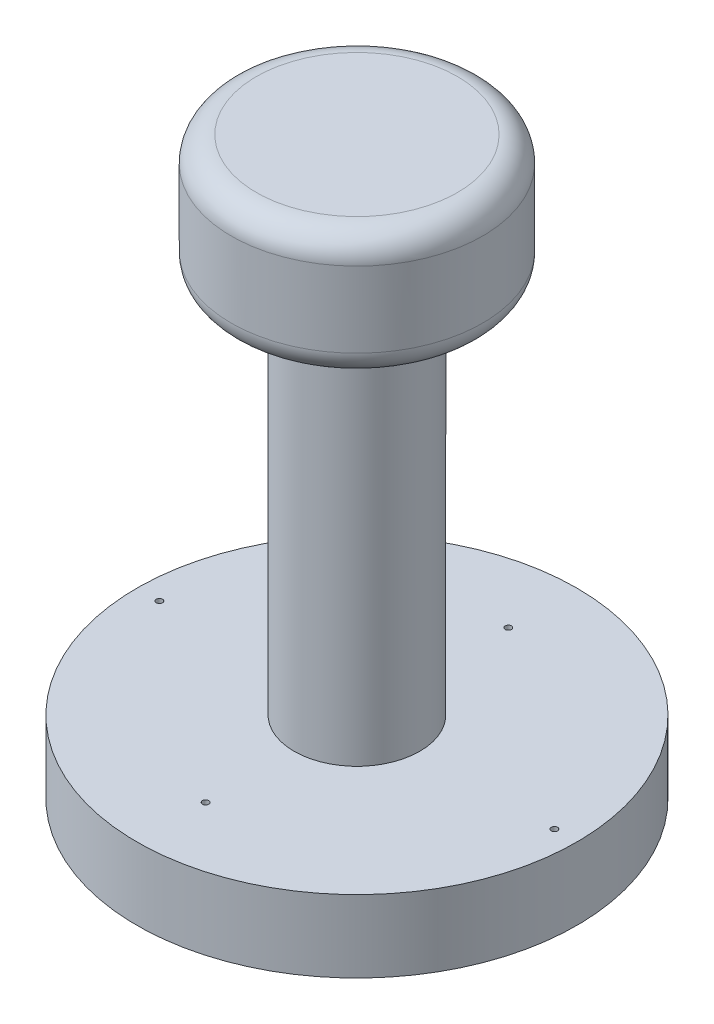
from build123d import *

# Parameters (mm, degrees)
SKETCH1_W            = 10
SKETCH1_H            = 10
FILLET1_R            = 2
FILLET2_R            = 2
SKETCH2_R            = 5
BOSS_EXTRUDE1_DEPTH  = 30
SKETCH3_R            = 17.5
BOSS_EXTRUDE2_DEPTH  = 5
SKETCH4_R            = 17.5
SKETCH4_R_2          = 17.25
BOSS_EXTRUDE4_DEPTH  = 0.75
SKETCH5_W            = 28.357054984
SKETCH5_H            = 13.671265806
SKETCH5_W_2          = 27.36
SKETCH5_H_2          = 12.67056155
BOSS_EXTRUDE5_DEPTH  = 0.75
FILLET3_R            = 2
FILLET4_R            = 2
FILLET5_R            = 2
FILLET6_R            = 2
FILLET9_R            = 2
FILLET10_R           = 2
FILLET11_R           = 2
FILLET12_R           = 2
SKETCH8_W            = 0.5
SKETCH8_H            = 2.723447839
BOSS_EXTRUDE7_DEPTH  = 0.75
SKETCH9_R            = 2.516469436
SKETCH9_R_2          = 1.509887237
SKETCH9_R_3          = 1.01085601
BOSS_EXTRUDE8_DEPTH  = 0.75
FILLET13_R           = 2
FILLET14_R           = 2
BOSS_EXTRUDE10_DEPTH = 0.75
BOSS_EXTRUDE11_DEPTH = 0.75
BOSS_EXTRUDE12_DEPTH = 0.75
BOSS_EXTRUDE14_DEPTH = 0.75
SKETCH20_R           = 0.25
CUT_EXTRUDE1_DEPTH   = 5
SKETCH23_R           = 0.25
CUT_EXTRUDE2_DEPTH   = 5
SKETCH24_R           = 0.25
CUT_EXTRUDE3_DEPTH   = 5
SKETCH25_R           = 0.25
CUT_EXTRUDE4_DEPTH   = 5


with BuildPart() as part:
    # Sketch1 → Revolve1 (revolve)
    with BuildSketch(Plane.XY):
        Rectangle(SKETCH1_W, SKETCH1_H)
    revolve(axis=Axis((5, -5, 0), (0, 1, 0)))

    # Fillet1
    fillet1_edges = [part.edges().sort_by_distance(p)[0] for p in [
        (15, 5, 0),
    ]]
    fillet(fillet1_edges, radius=FILLET1_R)

    # Fillet2
    fillet2_edges = [part.edges().sort_by_distance(p)[0] for p in [
        (15, -5, 0),
    ]]
    fillet(fillet2_edges, radius=FILLET2_R)

    # Sketch2 → Boss-Extrude1 (add)
    with BuildSketch(Plane(origin=(0, -5, 0), x_dir=(-1, 0, 0), z_dir=(0, -1, 0))):
        with Locations((-5, 0)):
            Circle(SKETCH2_R)
    extrude(amount=BOSS_EXTRUDE1_DEPTH)

    # Sketch3 → Boss-Extrude2 (add)
    with BuildSketch(Plane(origin=(0, -35, 0), x_dir=(-1, 0, 0), z_dir=(0, -1, 0))):
        with Locations((-5, 0)):
            Circle(SKETCH3_R)
    extrude(amount=BOSS_EXTRUDE2_DEPTH)

    # Sketch4 → Boss-Extrude4 (add)
    with BuildSketch(Plane(origin=(0, -40, 0), x_dir=(-1, 0, 0), z_dir=(0, -1, 0))):
        with Locations((-5, 0)):
            Circle(SKETCH4_R)
        with Locations((-5, 0)):
            Circle(SKETCH4_R_2, mode=Mode.SUBTRACT)
    extrude(amount=BOSS_EXTRUDE4_DEPTH)

    # Sketch5 → Boss-Extrude5 (add)
    with BuildSketch(Plane(origin=(0, -40, 0), x_dir=(-1, 0, 0), z_dir=(0, -1, 0))):
        with Locations((-5, 0)):
            Rectangle(SKETCH5_W, SKETCH5_H)
        with Locations((-5, 0)):
            Rectangle(SKETCH5_W_2, SKETCH5_H_2, mode=Mode.SUBTRACT)
    extrude(amount=BOSS_EXTRUDE5_DEPTH)

    # Fillet3
    fillet3_edges = [part.edges().sort_by_distance(p)[0] for p in [
        (-8.68, -40.375, 6.335280775),
    ]]
    fillet(fillet3_edges, radius=FILLET3_R)

    # Fillet4
    fillet4_edges = [part.edges().sort_by_distance(p)[0] for p in [
        (-9.178527492, -40.375, 6.835632903),
    ]]
    fillet(fillet4_edges, radius=FILLET4_R)

    # Fillet5
    fillet5_edges = [part.edges().sort_by_distance(p)[0] for p in [
        (18.68, -40.375, 6.335280775),
    ]]
    fillet(fillet5_edges, radius=FILLET5_R)

    # Fillet6
    fillet6_edges = [part.edges().sort_by_distance(p)[0] for p in [
        (19.178527492, -40.375, 6.835632903),
    ]]
    fillet(fillet6_edges, radius=FILLET6_R)

    # Fillet9
    fillet9_edges = [part.edges().sort_by_distance(p)[0] for p in [
        (18.68, -40.375, -6.335280775),
    ]]
    fillet(fillet9_edges, radius=FILLET9_R)

    # Fillet10
    fillet10_edges = [part.edges().sort_by_distance(p)[0] for p in [
        (19.178527492, -40.375, -6.835632903),
    ]]
    fillet(fillet10_edges, radius=FILLET10_R)

    # Fillet11
    fillet11_edges = [part.edges().sort_by_distance(p)[0] for p in [
        (-8.68, -40.375, -6.335280775),
    ]]
    fillet(fillet11_edges, radius=FILLET11_R)

    # Fillet12
    fillet12_edges = [part.edges().sort_by_distance(p)[0] for p in [
        (-9.178527492, -40.375, -6.835632903),
    ]]
    fillet(fillet12_edges, radius=FILLET12_R)

    # Sketch8 → Boss-Extrude7 (add)
    with BuildSketch(Plane.XZ.offset(40)):
        with Locations((-3.698250587, -1.36172392)):
            Rectangle(SKETCH8_W, SKETCH8_H)
        Polygon((-3.448250587, -2.723447839), (-3.948250587, -2.723447839), (-3.948250587, -3.223447839), (7.130563459, -3.223447839), (7.130563459, -2.723447839), align=None)
    extrude(amount=BOSS_EXTRUDE7_DEPTH)

    # Sketch9 → Boss-Extrude8 (add)
    with BuildSketch(Plane(origin=(0, -40, 0), x_dir=(-1, 0, 0), z_dir=(0, -1, 0))):
        with Locations((-17.460950076, -5.133055929)):
            Circle(SKETCH9_R)
        with Locations((-14.94448064, -8.642235551)):
            Circle(SKETCH9_R_2)
        with Locations((-17.969915059, -8.936899488)):
            Circle(SKETCH9_R_3)
    extrude(amount=BOSS_EXTRUDE8_DEPTH)

    # Fillet13
    fillet13_edges = [part.edges().sort_by_distance(p)[0] for p in [
        (-3.448250587, -40.375, -2.723447839),
    ]]
    fillet(fillet13_edges, radius=FILLET13_R)

    # Fillet14
    fillet14_edges = [part.edges().sort_by_distance(p)[0] for p in [
        (-3.948250587, -40.375, -3.223447839),
    ]]
    fillet(fillet14_edges, radius=FILLET14_R)

    # Sketch15 → Boss-Extrude10 (add)
    with BuildSketch(Plane(origin=(0, -40, 0), x_dir=(-1, 0, 0), z_dir=(0, -1, 0))):
        Polygon((-9.246204562, -2.487406617), (-9.246204562, 1.012593383), (-9.312110011, 1.012593383), (-11.62440969, -1.742114149), (-11.62440969, 1.012593383), (-11.938512254, 1.012593383), (-11.938512254, -2.487406617), (-11.866997831, -2.487406617), (-9.560307126, 0.260990819), (-9.560307126, -2.487406617), align=None)
    extrude(amount=BOSS_EXTRUDE10_DEPTH)

    # Sketch16 → Boss-Extrude11 (add)
    with BuildSketch(Plane(origin=(0, -40, 0), x_dir=(-1, 0, 0), z_dir=(0, -1, 0))):
        with BuildLine():
            add(Edge.make_bspline(
                [(-6.96372979, 1.117976908), (-7.028537896, 1.116335429), (-7.155826363, 1.113111428), (-7.34290126, 1.088432325), (-7.521496356, 1.045736935), (-7.693066495, 0.988873952), (-7.855559471, 0.913019567), (-8.010198364, 0.821334418), (-8.156615237, 0.71285796), (-8.292836619, 0.588428733), (-8.417493569, 0.453045279), (-8.527319456, 0.308567369), (-8.619361749, 0.155868566), (-8.694947536, -0.004592264), (-8.754246146, -0.172452232), (-8.79516519, -0.348606235), (-8.82130334, -0.531912925), (-8.824359117, -0.65693979), (-8.825909277, -0.720364438)],
                knots=[0, 0, 0, 0, 0.000194393, 0.000381804, 0.00056479, 0.000744601, 0.000923091, 0.001101652, 0.001283106, 0.001468738, 0.001654324, 0.001834514, 0.002012231, 0.002188181, 0.002365797, 0.002545211, 0.002729936, 0.002920126, 0.002920126, 0.002920126, 0.002920126], degree=3))
            add(Edge.make_bspline(
                [(-8.825909277, -0.720364438), (-8.824359345, -0.783321884), (-8.821304248, -0.907418305), (-8.79513547, -1.089561749), (-8.75409447, -1.264652445), (-8.695498204, -1.432398098), (-8.620272726, -1.592975662), (-8.527617555, -1.745962616), (-8.418476344, -1.891409114), (-8.294269493, -2.027721779), (-8.158868451, -2.15271925), (-8.013638184, -2.261638126), (-7.861844864, -2.35536225), (-7.701535156, -2.430145924), (-7.534835119, -2.489917845), (-7.360252796, -2.530670475), (-7.178606242, -2.556957518), (-7.054735238, -2.559976034), (-6.991774662, -2.561510271)],
                knots=[0, 0, 0, 0, 0.000188789, 0.000372126, 0.000550857, 0.00072758, 0.000904164, 0.001081881, 0.001263191, 0.001448823, 0.00163441, 0.001815159, 0.001992641, 0.002168591, 0.002344885, 0.002522934, 0.002705576, 0.002894365, 0.002894365, 0.002894365, 0.002894365], degree=3))
            add(Edge.make_bspline(
                [(-6.991774662, -2.561510271), (-6.928350343, -2.559960884), (-6.803324127, -2.55690663), (-6.619787091, -2.530725226), (-6.443509348, -2.489783922), (-6.274994996, -2.431274486), (-6.114150067, -2.355657255), (-5.960659984, -2.263452876), (-5.815140837, -2.154045735), (-5.67879909, -2.02987916), (-5.554049892, -1.894707608), (-5.445290516, -1.749873353), (-5.353065403, -1.598217896), (-5.277702071, -1.439320372), (-5.218037611, -1.273948929), (-5.177332793, -1.101000452), (-5.150996841, -0.921460946), (-5.147961995, -0.799218048), (-5.146422098, -0.737191361)],
                knots=[0, 0, 0, 0, 0.00019019, 0.000374915, 0.000555011, 0.000732396, 0.00090898, 0.001087298, 0.001268608, 0.00145424, 0.001639827, 0.001819595, 0.001996712, 0.002171394, 0.002346367, 0.002523053, 0.002703612, 0.002889599, 0.002889599, 0.002889599, 0.002889599], degree=3))
            add(Edge.make_bspline(
                [(-5.146422098, -0.737191361), (-5.146956733, -0.695558692), (-5.148019259, -0.612818568), (-5.160810952, -0.489951968), (-5.179372653, -0.36906131), (-5.205974566, -0.250490362), (-5.240766233, -0.134529378), (-5.28181826, -0.020378615), (-5.331958105, 0.090805109), (-5.388638753, 0.199548501), (-5.451900561, 0.304156407), (-5.521776311, 0.40303599), (-5.595811679, 0.497016986), (-5.676975073, 0.58366399), (-5.762591518, 0.665497647), (-5.854049896, 0.741260364), (-5.950792141, 0.811635315), (-6.05323452, 0.875055656), (-6.158852795, 0.93241479), (-6.267729573, 0.981636641), (-6.378386145, 1.023882703), (-6.491340793, 1.058123528), (-6.606293565, 1.085155564), (-6.723495349, 1.103562918), (-6.842852776, 1.116387236), (-6.923264094, 1.117444738), (-6.96372979, 1.117976908)],
                knots=[0, 0, 0, 0, 0.000124849, 0.000248123, 0.000370193, 0.00049164, 0.000612319, 0.000733199, 0.000855287, 0.000977905, 0.001100913, 0.001221706, 0.001340948, 0.001459521, 0.001577551, 0.001696047, 0.001815534, 0.001936153, 0.002057243, 0.002175846, 0.002294342, 0.002412335, 0.002529682, 0.00264829, 0.002768075, 0.00288942, 0.00288942, 0.00288942, 0.00288942], degree=3))
        make_face()
        with BuildLine():
            add(Edge.make_bspline(
                [(-6.979154469, 0.759002549), (-6.945939836, 0.758597659), (-6.879828103, 0.757791749), (-6.781543567, 0.747176034), (-6.684551633, 0.732046145), (-6.588832271, 0.710464624), (-6.494785981, 0.681060571), (-6.40153614, 0.647219663), (-6.309933086, 0.605998573), (-6.220279228, 0.559425868), (-6.133364153, 0.507876947), (-6.051351452, 0.45090518), (-5.974028808, 0.389846626), (-5.901585541, 0.324558789), (-5.834234369, 0.254709187), (-5.770649668, 0.181356751), (-5.713380086, 0.10240486), (-5.660894509, 0.019994453), (-5.613926669, -0.065767128), (-5.572161314, -0.153976991), (-5.537997305, -0.245354677), (-5.510134929, -0.338908835), (-5.487035118, -0.434491295), (-5.472401194, -0.532827143), (-5.461668835, -0.633422255), (-5.460908989, -0.701404109), (-5.460524662, -0.735789117)],
                knots=[0, 0, 0, 0, 9.9599e-05, 0.000198245, 0.000296222, 0.00039402, 0.00049227, 0.000591646, 0.000691452, 0.000793368, 0.000894612, 0.000994383, 0.001092713, 0.00119001, 0.001286696, 0.001383657, 0.001480979, 0.001579008, 0.001676595, 0.001774142, 0.001871547, 0.001968922, 0.002066879, 0.00216624, 0.00226698, 0.002370083, 0.002370083, 0.002370083, 0.002370083], degree=3))
            add(Edge.make_bspline(
                [(-5.460524662, -0.735789117), (-5.461799524, -0.786351338), (-5.464307572, -0.885822868), (-5.486265142, -1.031591012), (-5.520087116, -1.171679299), (-5.569944483, -1.305321208), (-5.632295097, -1.433665491), (-5.709321987, -1.555573595), (-5.800581073, -1.67107847), (-5.9042446, -1.779373739), (-6.017567306, -1.878219543), (-6.137900036, -1.964982952), (-6.263953644, -2.038393201), (-6.396056846, -2.098198274), (-6.533504385, -2.145588012), (-6.677181936, -2.178066643), (-6.826132396, -2.199442098), (-6.927663051, -2.201494854), (-6.979154469, -2.202535912)],
                knots=[0, 0, 0, 0, 0.000151605, 0.000298253, 0.000441263, 0.000583229, 0.000725274, 0.000868635, 0.001014928, 0.001166177, 0.001317744, 0.00146543, 0.001610576, 0.001754594, 0.001899821, 0.002045914, 0.002195936, 0.002350312, 0.002350312, 0.002350312, 0.002350312], degree=3))
            add(Edge.make_bspline(
                [(-6.979154469, -2.202535912), (-7.013763971, -2.202060408), (-7.082405007, -2.20111734), (-7.18450053, -2.191618663), (-7.284756741, -2.176386794), (-7.383033021, -2.154456138), (-7.479217833, -2.127008932), (-7.573712636, -2.094401204), (-7.665510926, -2.05372), (-7.755770764, -2.008772048), (-7.842167006, -1.957531891), (-7.924642538, -1.902493741), (-8.001118518, -1.84152512), (-8.073507589, -1.777207308), (-8.141135278, -1.70824346), (-8.203544262, -1.634723238), (-8.260524395, -1.556182581), (-8.312990041, -1.473897175), (-8.359793304, -1.387900922), (-8.400572403, -1.299371245), (-8.435168519, -1.208526135), (-8.463097024, -1.115234564), (-8.484982485, -1.019673715), (-8.500062405, -0.921715637), (-8.510610844, -0.821556294), (-8.511405921, -0.753812438), (-8.511806713, -0.719663316)],
                knots=[0, 0, 0, 0, 0.000103804, 0.000205874, 0.000307314, 0.000407849, 0.000507719, 0.000607281, 0.000707445, 0.000808723, 0.000909609, 0.001008589, 0.001105934, 0.001202762, 0.001298946, 0.001395452, 0.001491794, 0.001589823, 0.001688026, 0.001785277, 0.001882027, 0.001979402, 0.0020772, 0.002175869, 0.002276609, 0.002379011, 0.002379011, 0.002379011, 0.002379011], degree=3))
            add(Edge.make_bspline(
                [(-8.511806713, -0.719663316), (-8.5114056, -0.685747812), (-8.510609919, -0.618470162), (-8.500067444, -0.519009343), (-8.484966554, -0.421756132), (-8.463203845, -0.327092329), (-8.435153692, -0.234993804), (-8.400566361, -0.145547056), (-8.359781062, -0.058418861), (-8.312972838, 0.026175436), (-8.260357014, 0.107350174), (-8.202862771, 0.184952587), (-8.139497423, 0.257525328), (-8.072071398, 0.326860022), (-7.998900512, 0.391477912), (-7.920316218, 0.451400432), (-7.837272541, 0.508073707), (-7.749345305, 0.559199268), (-7.658601351, 0.606413501), (-7.565487393, 0.646864504), (-7.471058294, 0.681236624), (-7.375554181, 0.710553589), (-7.278171203, 0.731961619), (-7.179567374, 0.747189669), (-7.079879116, 0.757788055), (-7.012835896, 0.758596433), (-6.979154469, 0.759002549)],
                knots=[0, 0, 0, 0, 0.000101701, 0.000201743, 0.00029972, 0.000396835, 0.000492868, 0.000588308, 0.000684288, 0.000781261, 0.000878109, 0.000974304, 0.001070733, 0.001166917, 0.001264269, 0.001363274, 0.001463228, 0.001565678, 0.001668217, 0.001769947, 0.001869982, 0.001969573, 0.002069423, 0.002168785, 0.002268827, 0.002369827, 0.002369827, 0.002369827, 0.002369827], degree=3))
        make_face(mode=Mode.SUBTRACT)
    extrude(amount=BOSS_EXTRUDE11_DEPTH)

    # Sketch17 → Boss-Extrude12 (add)
    with BuildSketch(Plane(origin=(0, -40, 0), x_dir=(-1, 0, 0), z_dir=(0, -1, 0))):
        with BuildLine():
            Line((-1.433170212, 0.303677722), (-1.708009956, 0.093341183))
            add(Edge.make_bspline(
                [(-1.708009956, 0.093341183), (-1.727615844, 0.116707153), (-1.766563291, 0.163124069), (-1.829222493, 0.228303613), (-1.894524136, 0.289368875), (-1.962443257, 0.346610754), (-2.034202377, 0.39802752), (-2.108063175, 0.446298623), (-2.185261221, 0.489566361), (-2.292012955, 0.542029347), (-2.431660804, 0.596775502), (-2.607455643, 0.642678733), (-2.790966741, 0.671899909), (-2.916164341, 0.67506475), (-2.979844891, 0.676674516)],
                knots=[0, 0, 0, 0, 9.1485e-05, 0.000181737, 0.000271024, 0.000359627, 0.000447979, 0.000535687, 0.000624217, 0.000713268, 0.000892422, 0.00107303, 0.001257466, 0.001448389, 0.001448389, 0.001448389, 0.001448389], degree=3))
            add(Edge.make_bspline(
                [(-2.979844891, 0.676674516), (-3.014928191, 0.676270554), (-3.084769183, 0.675466378), (-3.188417657, 0.664857253), (-3.290130708, 0.649946043), (-3.389842174, 0.62782072), (-3.487425133, 0.599848101), (-3.583517535, 0.566422687), (-3.676728135, 0.525067847), (-3.768346373, 0.479359587), (-3.856125584, 0.427732142), (-3.939180632, 0.37141879), (-4.017208599, 0.311049694), (-4.090271212, 0.246398587), (-4.15844316, 0.177756627), (-4.221230471, 0.104392285), (-4.278415881, 0.026540112), (-4.331132906, -0.054773296), (-4.378345639, -0.139311087), (-4.417875519, -0.227386158), (-4.452880641, -0.317490261), (-4.480579884, -0.410641422), (-4.502504401, -0.506184188), (-4.517632064, -0.604374976), (-4.528120535, -0.705008655), (-4.528920712, -0.773217968), (-4.529324058, -0.807600323)],
                knots=[0, 0, 0, 0, 0.000105206, 0.000209435, 0.000312261, 0.00041348, 0.000515565, 0.000616682, 0.000718413, 0.000821258, 0.000923708, 0.001023662, 0.001122111, 0.001219464, 0.00131614, 0.001412112, 0.001508869, 0.001605718, 0.001702691, 0.001799013, 0.001895107, 0.001992482, 0.002090281, 0.00218895, 0.002290387, 0.00239349, 0.00239349, 0.00239349, 0.00239349], degree=3))
            add(Edge.make_bspline(
                [(-4.529324058, -0.807600323), (-4.528062239, -0.859331643), (-4.525584825, -0.960899228), (-4.503536491, -1.109669839), (-4.470031399, -1.252190512), (-4.419815822, -1.387570355), (-4.357896772, -1.517478713), (-4.27965616, -1.639717566), (-4.189039623, -1.756134131), (-4.084765204, -1.863977078), (-3.970359388, -1.962490804), (-3.847611476, -2.049241385), (-3.716827188, -2.121556268), (-3.579450558, -2.181732214), (-3.434424444, -2.227988942), (-3.282009642, -2.260553065), (-3.122537646, -2.281795246), (-3.013568247, -2.283828934), (-2.958110116, -2.284863945)],
                knots=[0, 0, 0, 0, 0.000155106, 0.000304531, 0.000450265, 0.000593548, 0.000736853, 0.000881182, 0.001028026, 0.001178769, 0.001330408, 0.001480379, 0.001628835, 0.001777978, 0.001929641, 0.002084627, 0.002245075, 0.00241136, 0.00241136, 0.00241136, 0.00241136], degree=3))
            add(Edge.make_bspline(
                [(-2.958110116, -2.284863945), (-2.897007427, -2.283175165), (-2.776742718, -2.279851243), (-2.600374692, -2.251691994), (-2.431538926, -2.206034076), (-2.270226339, -2.142136154), (-2.116891693, -2.059070866), (-1.971295033, -1.958372988), (-1.833313462, -1.839084655), (-1.75034218, -1.748001527), (-1.708009956, -1.701530612)],
                knots=[0, 0, 0, 0, 0.00018322, 0.00036062, 0.000534275, 0.000707044, 0.000879893, 0.001056289, 0.001237208, 0.001425665, 0.001425665, 0.001425665, 0.001425665], degree=3))
            Line((-1.708009956, -1.701530612), (-1.433170212, -1.909763785))
            add(Edge.make_bspline(
                [(-1.433170212, -1.909763785), (-1.455288322, -1.938302237), (-1.499418597, -1.995242443), (-1.570876614, -2.075514153), (-1.646153911, -2.151018188), (-1.725809621, -2.221145809), (-1.808927413, -2.287300275), (-1.896999725, -2.347602106), (-1.988868758, -2.402892991), (-2.084223237, -2.453519915), (-2.18296185, -2.498437162), (-2.284966285, -2.53689093), (-2.38979686, -2.57001582), (-2.497458368, -2.597267756), (-2.608174125, -2.61853884), (-2.721544599, -2.632758515), (-2.837814475, -2.642500429), (-2.916255896, -2.643388345), (-2.95600675, -2.643838304)],
                knots=[0, 0, 0, 0, 0.000108293, 0.000216068, 0.000322162, 0.000427957, 0.000534281, 0.00064066, 0.000747915, 0.000855806, 0.000964371, 0.001073102, 0.001182643, 0.001294024, 0.001406092, 0.001520624, 0.001636667, 0.001755891, 0.001755891, 0.001755891, 0.001755891], degree=3))
            add(Edge.make_bspline(
                [(-2.95600675, -2.643838304), (-2.993650417, -2.643576312), (-3.068086108, -2.643058254), (-3.177984859, -2.634666086), (-3.28497444, -2.623216349), (-3.388749066, -2.605976218), (-3.489875041, -2.585631878), (-3.587435625, -2.558360622), (-3.682390836, -2.527811455), (-3.774359176, -2.491906468), (-3.863418876, -2.451390286), (-3.949282688, -2.405598727), (-4.03191112, -2.354916862), (-4.112116541, -2.300461852), (-4.188714125, -2.24048455), (-4.26236765, -2.175817915), (-4.333490126, -2.106679905), (-4.377492811, -2.056825051), (-4.399616526, -2.031758977)],
                knots=[0, 0, 0, 0, 0.0001129, 0.000223246, 0.000330481, 0.000435603, 0.000538732, 0.000639764, 0.000739316, 0.000837878, 0.000935767, 0.001032686, 0.001129604, 0.00122645, 0.001323362, 0.001421241, 0.001520399, 0.001620667, 0.001620667, 0.001620667, 0.001620667], degree=3))
            add(Edge.make_bspline(
                [(-4.399616526, -2.031758977), (-4.43505217, -1.988217788), (-4.505495646, -1.901661078), (-4.59562133, -1.761375097), (-4.672768885, -1.614906888), (-4.735144806, -1.461486959), (-4.783907539, -1.301459572), (-4.817688734, -1.134744057), (-4.839640339, -0.961496115), (-4.842150627, -0.843659326), (-4.843426622, -0.783762182)],
                knots=[0, 0, 0, 0, 0.000168306, 0.00033458, 0.000499224, 0.000664315, 0.00083066, 0.00100034, 0.001174094, 0.001353718, 0.001353718, 0.001353718, 0.001353718], degree=3))
            add(Edge.make_bspline(
                [(-4.843426622, -0.783762182), (-4.841871429, -0.720806729), (-4.838811682, -0.596945804), (-4.812815887, -0.415171851), (-4.770997091, -0.241020452), (-4.711600202, -0.074816707), (-4.636294851, 0.084313573), (-4.543268237, 0.235154778), (-4.433601095, 0.378671577), (-4.308153527, 0.512686329), (-4.170586192, 0.635225681), (-4.023267378, 0.743031885), (-3.866485431, 0.832749401), (-3.701967579, 0.907745563), (-3.528481898, 0.965390027), (-3.346398529, 1.005743213), (-3.156059614, 1.030860329), (-3.026197188, 1.034035537), (-2.960213481, 1.035648875)],
                knots=[0, 0, 0, 0, 0.000188789, 0.000371431, 0.000549644, 0.000725278, 0.00089996, 0.001076844, 0.001255917, 0.001440951, 0.001626689, 0.001807878, 0.001987546, 0.002167657, 0.002349462, 0.002534866, 0.002726448, 0.002924344, 0.002924344, 0.002924344, 0.002924344], degree=3))
            add(Edge.make_bspline(
                [(-2.960213481, 1.035648875), (-2.919999009, 1.035166737), (-2.840398512, 1.034212393), (-2.72264586, 1.024906251), (-2.608003533, 1.009392645), (-2.496392551, 0.988276575), (-2.387269934, 0.962069254), (-2.281469693, 0.927928955), (-2.178371007, 0.888892424), (-2.078624098, 0.843933958), (-1.982707548, 0.793467217), (-1.89065123, 0.738051593), (-1.803186371, 0.677755788), (-1.719697523, 0.613092612), (-1.641581312, 0.542694053), (-1.566619833, 0.468496457), (-1.497358755, 0.388362633), (-1.45460556, 0.331957699), (-1.433170212, 0.303677722)],
                knots=[0, 0, 0, 0, 0.000120626, 0.000238766, 0.000354085, 0.000467531, 0.000579423, 0.000690512, 0.000800803, 0.000910007, 0.001018518, 0.001125773, 0.001232152, 0.001337058, 0.001442329, 0.001547432, 0.001653292, 0.001759736, 0.001759736, 0.001759736, 0.001759736], degree=3))
        make_face()
    extrude(amount=BOSS_EXTRUDE12_DEPTH)

    # Sketch19 → Boss-Extrude14 (add)
    with BuildSketch(Plane(origin=(0, -40, 0), x_dir=(-1, 0, 0), z_dir=(0, -1, 0))):
        Polygon((-0.988394156, -2.53590749), (0.985964818, -2.53590749), (0.985964818, -2.176933131), (-0.674291592, -2.176933131), (-0.674291592, -1.100010054), (0.985964818, -1.100010054), (0.985964818, -0.741035695), (-0.674291592, -0.741035695), (-0.674291592, 0.605118151), (0.985964818, 0.605118151), (0.985964818, 0.96409251), (-0.988394156, 0.96409251), align=None)
    extrude(amount=BOSS_EXTRUDE14_DEPTH)

    # Sketch20 → Cut-Extrude1 (cut)
    with BuildSketch(Plane(origin=(0, -40, 0), x_dir=(-1, 0, 0), z_dir=(0, -1, 0))):
        with Locations((-5, 12.042816452)):
            Circle(SKETCH20_R)
    extrude(amount=-CUT_EXTRUDE1_DEPTH, mode=Mode.SUBTRACT)

    # Sketch23 → Cut-Extrude2 (cut)
    with BuildSketch(Plane(origin=(0, -40, 0), x_dir=(-1, 0, 0), z_dir=(0, -1, 0))):
        with Locations((-5, -12.042816452)):
            Circle(SKETCH23_R)
    extrude(amount=-CUT_EXTRUDE2_DEPTH, mode=Mode.SUBTRACT)

    # Sketch24 → Cut-Extrude3 (cut)
    with BuildSketch(Plane(origin=(0, -40, 0), x_dir=(-1, 0, 0), z_dir=(0, -1, 0))):
        with Locations((10.714263746, 0)):
            Circle(SKETCH24_R)
    extrude(amount=-CUT_EXTRUDE3_DEPTH, mode=Mode.SUBTRACT)

    # Sketch25 → Cut-Extrude4 (cut)
    with BuildSketch(Plane(origin=(0, -40, 0), x_dir=(-1, 0, 0), z_dir=(0, -1, 0))):
        with Locations((-20.714263746, 0)):
            Circle(SKETCH25_R)
    extrude(amount=-CUT_EXTRUDE4_DEPTH, mode=Mode.SUBTRACT)


solid = part.part
